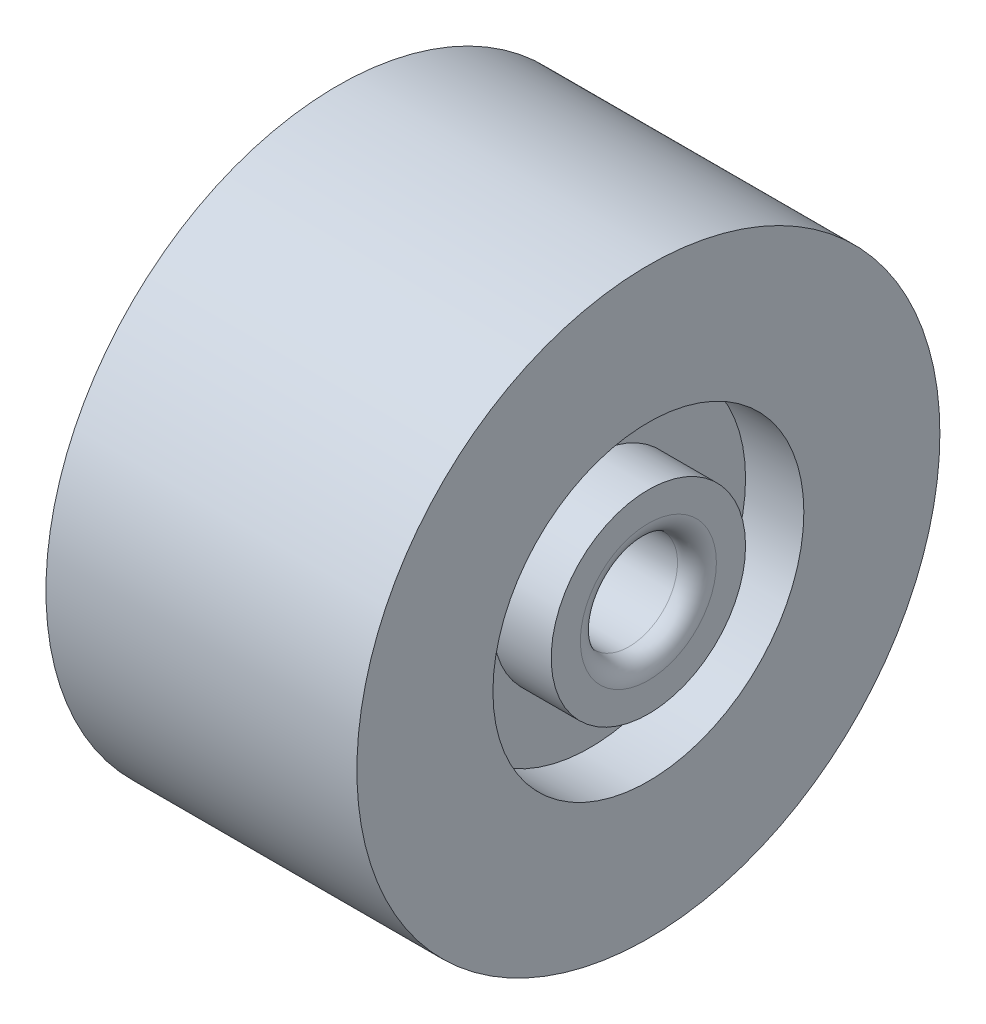
from build123d import *

# Parameters (mm, degrees)
SKETCH2_R          = 2.5
CUT_EXTRUDE1_DEPTH = 16
FILLET1_R          = 1


with BuildPart() as part:
    # Sketch1 → Revolve2 (revolve)
    with BuildSketch(Plane.XY):
        Polygon((0, 2.5), (-3, 2.5), (-3, 5.5), (0, 5.5), (0, 12.5), (-16, 12.5), (-16, 5.5), (-13, 5.5), (-13, 2.5), (-16, 2.5), (-16, -2.5), (0, -2.5), align=None)
    revolve(axis=Axis((8.187259668, -2.5, 0), (-1, 0, 0)))

    # Sketch2 → Cut-Extrude1 (cut)
    with BuildSketch(Plane.ZY.offset(16)):
        with Locations((0, -2.5)):
            Circle(SKETCH2_R)
    extrude(amount=-CUT_EXTRUDE1_DEPTH, mode=Mode.SUBTRACT)

    # Fillet1
    fillet1_edges = [part.edges().sort_by_distance(p)[0] for p in [
        (-16, -2.5, -2.5),
        (0, -2.5, -2.5),
    ]]
    fillet(fillet1_edges, radius=FILLET1_R)


solid = part.part
